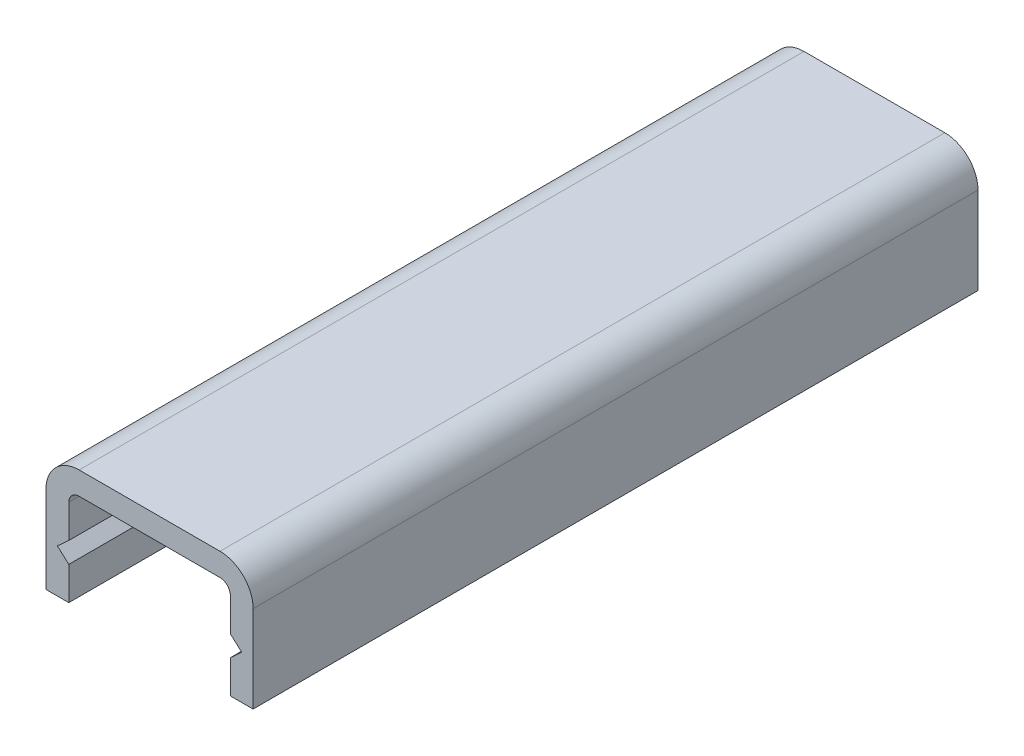
from build123d import *

# Parameters (mm, degrees)
EXTRUSION1_DEPTH = 35


with BuildPart() as part:
    # Esquisse1 → Extrusion1 (new body)
    with BuildSketch(Plane.XY):
        with BuildLine():
            Line((1.6, 0), (8.4, 0))
            ThreePointArc((8.4, 0), (9.53137085, -0.46862915), (10, -1.6))
            Line((10, -1.6), (10, -5.8))
            Line((10, -5.8), (8.9, -5.8))
            Line((8.9, -5.8), (8.9, -4.2))
            Line((8.9, -4.2), (9.45, -3.7))
            Line((9.45, -3.7), (8.9, -3.2))
            Line((8.9, -3.2), (8.9, -1.6))
            ThreePointArc((8.9, -1.6), (8.753553391, -1.246446609), (8.4, -1.1))
            Line((8.4, -1.1), (1.6, -1.1))
            ThreePointArc((1.6, -1.1), (1.246446609, -1.246446609), (1.1, -1.6))
            Line((1.1, -1.6), (1.1, -3.2))
            Line((1.1, -3.2), (0.55, -3.7))
            Line((0.55, -3.7), (1.1, -4.2))
            Line((1.1, -4.2), (1.1, -5.8))
            Line((1.1, -5.8), (0, -5.8))
            Line((0, -5.8), (0, -1.6))
            ThreePointArc((0, -1.6), (0.46862915, -0.46862915), (1.6, 0))
        make_face()
    extrude(amount=EXTRUSION1_DEPTH)


solid = part.part
